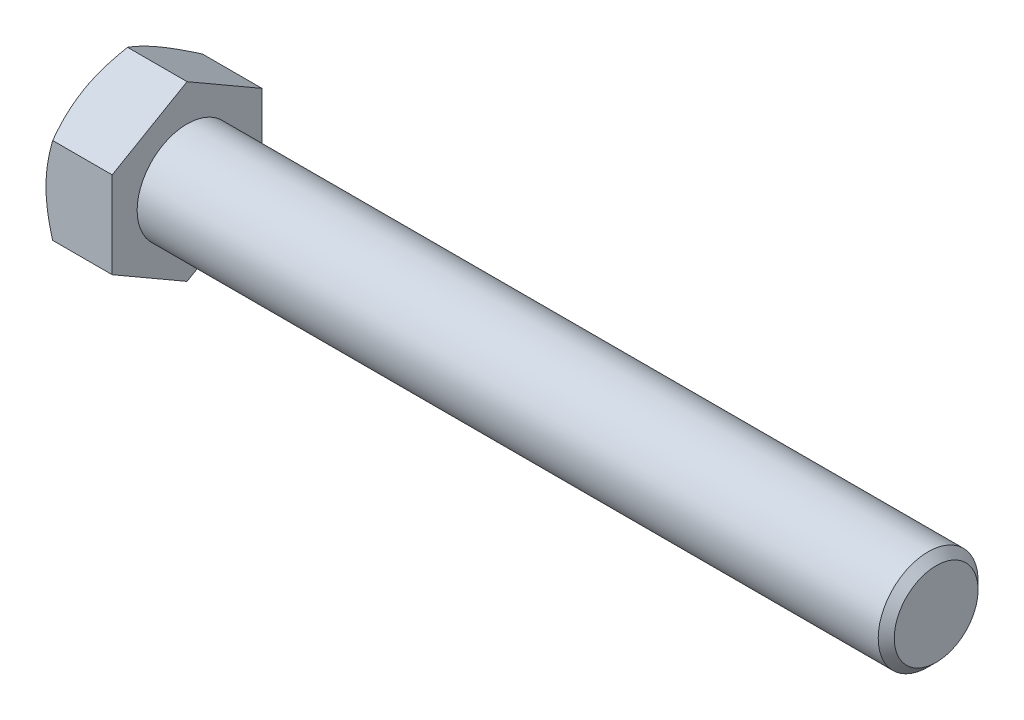
from build123d import *

# Parameters (mm, degrees)
BASEHEAD_DEPTH = 7.95


with BuildPart() as part:
    # Sketch1 → BaseHead (new body)
    with BuildSketch(Plane(origin=(0, 0, 0), x_dir=(0, 0, -1), z_dir=(1, 0, 0))):
        Polygon((9, 5.196152423), (9, -5.196152423), (0, -10.392304845), (-9, -5.196152423), (-9, 5.196152423), (0, 10.392304845), align=None)
    extrude(amount=BASEHEAD_DEPTH)

    # BodySke → BaseBody (revolve)
    with BuildSketch(Plane.XY):
        Polygon((0, 0), (97.95, 0), (97.95, 5.036), (96.986, 6), (0, 6), align=None)
    revolve(axis=Axis((0, 0, 0), (1, 0, 0)))

    # Sketch3 → HeadChamfer (revolve, cut)
    with BuildSketch(Plane.XY):
        Polygon((0, 9), (3.690598923, 15.392304845), (3.690598923, 20.392304845), (-10, 20.392304845), (-10, 9), align=None)
    revolve(axis=Axis((0, 0, 0), (1, 0, 0)), mode=Mode.SUBTRACT)


solid = part.part
